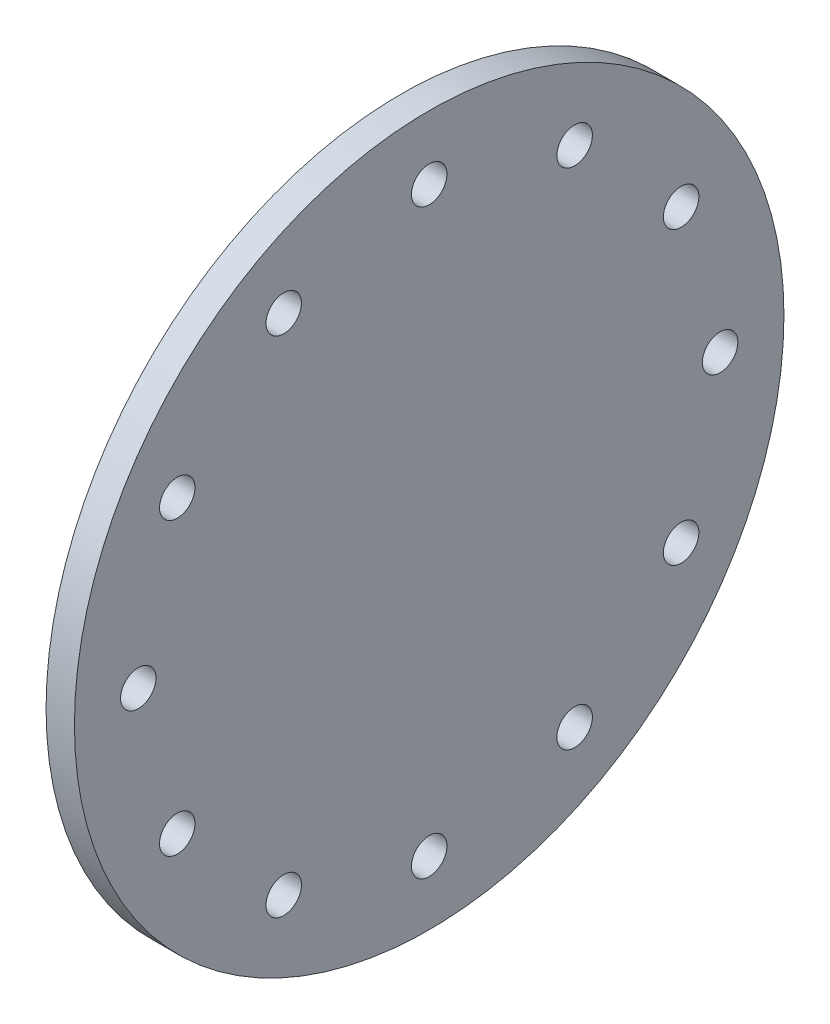
from build123d import *

# Parameters (mm, degrees)
SKETCH1_R           = 2500
SKETCH1_R_2         = 125
BOSS_EXTRUDE1_DEPTH = 200


with BuildPart() as part:
    # Sketch1 → Boss-Extrude1 (new body)
    with BuildSketch(Plane(origin=(0, 0, 0), x_dir=(0, 0, -1), z_dir=(1, 0, 0))):
        Circle(SKETCH1_R)
        with Locations((0, 2050)):
            Circle(SKETCH1_R_2, mode=Mode.SUBTRACT)
        with Locations((1025, 1775.352077758)):
            Circle(SKETCH1_R_2, mode=Mode.SUBTRACT)
        with Locations((1775.352077758, 1025)):
            Circle(SKETCH1_R_2, mode=Mode.SUBTRACT)
        with Locations((2050, 0)):
            Circle(SKETCH1_R_2, mode=Mode.SUBTRACT)
        with Locations((1775.352077758, -1025)):
            Circle(SKETCH1_R_2, mode=Mode.SUBTRACT)
        with Locations((1025, -1775.352077758)):
            Circle(SKETCH1_R_2, mode=Mode.SUBTRACT)
        with Locations((0, -2050)):
            Circle(SKETCH1_R_2, mode=Mode.SUBTRACT)
        with Locations((-1025, -1775.352077758)):
            Circle(SKETCH1_R_2, mode=Mode.SUBTRACT)
        with Locations((-1775.352077758, -1025)):
            Circle(SKETCH1_R_2, mode=Mode.SUBTRACT)
        with Locations((-2050, 0)):
            Circle(SKETCH1_R_2, mode=Mode.SUBTRACT)
        with Locations((-1775.352077758, 1025)):
            Circle(SKETCH1_R_2, mode=Mode.SUBTRACT)
        with Locations((-1025, 1775.352077758)):
            Circle(SKETCH1_R_2, mode=Mode.SUBTRACT)
    extrude(amount=BOSS_EXTRUDE1_DEPTH)


solid = part.part
